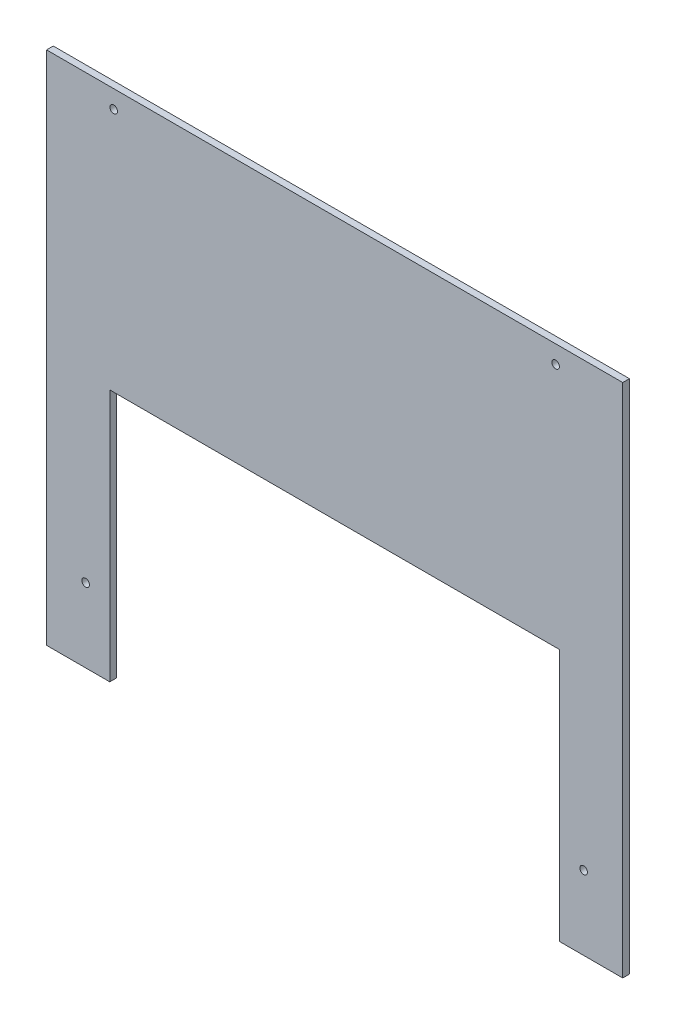
from build123d import *

# Parameters (mm, degrees)
ESQUISSE2_R        = 1.7
BOSS_EXTRU_1_DEPTH = 3


with BuildPart() as part:
    # Esquisse2 → Boss.-Extru.1 (new body)
    with BuildSketch(Plane.XY):
        Polygon((229.255, -230.48), (257.51, -230.48), (257.51, 0), (0, 0), (0, -230.48), (28.255, -230.48), (28.255, -117.48), (229.255, -117.48), align=None)
        with Locations((17.455, -197.48)):
            Circle(ESQUISSE2_R, mode=Mode.SUBTRACT)
        with Locations((240.055, -197.48)):
            Circle(ESQUISSE2_R, mode=Mode.SUBTRACT)
        with Locations((227.51, -8)):
            Circle(ESQUISSE2_R, mode=Mode.SUBTRACT)
        with Locations((30, -8)):
            Circle(ESQUISSE2_R, mode=Mode.SUBTRACT)
    extrude(amount=BOSS_EXTRU_1_DEPTH)


solid = part.part
